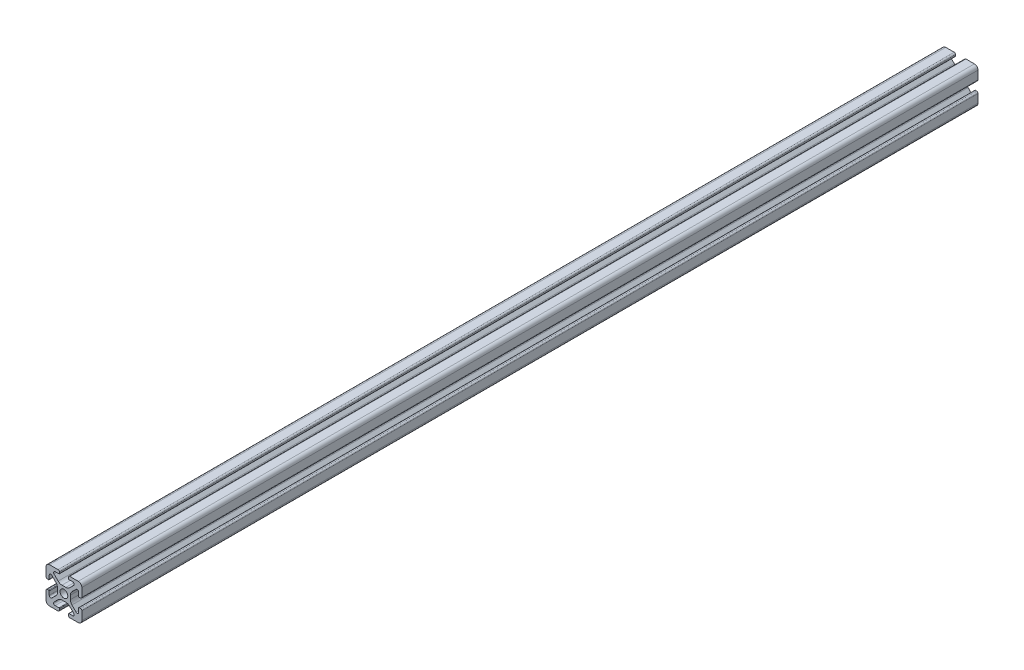
from build123d import *

# Parameters (mm, degrees)
SKETCH3_R                = 2.15
BOSS_EXTRUDE1_DEPTH      = 250
BOSS_EXTRUDE1_DEPTH_BACK = 250


with BuildPart() as part:
    # Sketch3 → Boss-Extrude1 (new body, two sides)
    with BuildSketch(Plane.XY) as boss_extrude1_sk:
        with BuildLine():
            Line((3.2874, 10), (8, 10))
            ThreePointArc((8, 10), (9.414213562, 9.414213562), (10, 8))
            Line((10, 8), (10, 3.2874))
            ThreePointArc((10, 3.2874), (9.76937588, 2.73062412), (9.2126, 2.5))
            Line((9.2126, 2.5), (8.5048, 2.5))
            ThreePointArc((8.5048, 2.5), (8.289273853, 2.589273853), (8.2, 2.8048))
            Line((8.2, 2.8048), (8.2, 4.9118))
            ThreePointArc((8.2, 4.9118), (7.682565253, 5.686195824), (6.769103096, 5.504496904))
            Line((6.769103096, 5.504496904), (4.478679656, 3.214073464))
            ThreePointArc((4.478679656, 3.214073464), (3.828361402, 2.240803418), (3.6, 1.092753121))
            Line((3.6, 1.092753121), (3.6, -1.092753121))
            ThreePointArc((3.6, -1.092753121), (3.828361402, -2.240803418), (4.478679656, -3.214073464))
            Line((4.478679656, -3.214073464), (6.769103096, -5.504496904))
            ThreePointArc((6.769103096, -5.504496904), (7.682565253, -5.686195824), (8.2, -4.9118))
            Line((8.2, -4.9118), (8.2, -2.8048))
            ThreePointArc((8.2, -2.8048), (8.289273853, -2.589273853), (8.5048, -2.5))
            Line((8.5048, -2.5), (9.2126, -2.5))
            ThreePointArc((9.2126, -2.5), (9.76937588, -2.73062412), (10, -3.2874))
            Line((10, -3.2874), (10, -8))
            ThreePointArc((10, -8), (9.414213562, -9.414213562), (8, -10))
            Line((8, -10), (3.2874, -10))
            ThreePointArc((3.2874, -10), (2.73062412, -9.76937588), (2.5, -9.2126))
            Line((2.5, -9.2126), (2.5, -8.5048))
            ThreePointArc((2.5, -8.5048), (2.589273853, -8.289273853), (2.8048, -8.2))
            Line((2.8048, -8.2), (4.9118, -8.2))
            ThreePointArc((4.9118, -8.2), (5.686195824, -7.682565253), (5.504496904, -6.769103096))
            Line((5.504496904, -6.769103096), (3.214073464, -4.478679656))
            ThreePointArc((3.214073464, -4.478679656), (2.240803418, -3.828361402), (1.092753121, -3.6))
            Line((1.092753121, -3.6), (-1.092753121, -3.6))
            ThreePointArc((-1.092753121, -3.6), (-2.240803418, -3.828361402), (-3.214073464, -4.478679656))
            Line((-3.214073464, -4.478679656), (-5.504496904, -6.769103096))
            ThreePointArc((-5.504496904, -6.769103096), (-5.686195824, -7.682565253), (-4.9118, -8.2))
            Line((-4.9118, -8.2), (-2.8048, -8.2))
            ThreePointArc((-2.8048, -8.2), (-2.589273853, -8.289273853), (-2.5, -8.5048))
            Line((-2.5, -8.5048), (-2.5, -9.2126))
            ThreePointArc((-2.5, -9.2126), (-2.73062412, -9.76937588), (-3.2874, -10))
            Line((-3.2874, -10), (-8, -10))
            ThreePointArc((-8, -10), (-9.414213562, -9.414213562), (-10, -8))
            Line((-10, -8), (-10, -3.2874))
            ThreePointArc((-10, -3.2874), (-9.76937588, -2.73062412), (-9.2126, -2.5))
            Line((-9.2126, -2.5), (-8.5048, -2.5))
            ThreePointArc((-8.5048, -2.5), (-8.289273853, -2.589273853), (-8.2, -2.8048))
            Line((-8.2, -2.8048), (-8.2, -4.9118))
            ThreePointArc((-8.2, -4.9118), (-7.682565253, -5.686195824), (-6.769103096, -5.504496904))
            Line((-6.769103096, -5.504496904), (-4.478679656, -3.214073464))
            ThreePointArc((-4.478679656, -3.214073464), (-3.828361402, -2.240803418), (-3.6, -1.092753121))
            Line((-3.6, -1.092753121), (-3.6, 1.092753121))
            ThreePointArc((-3.6, 1.092753121), (-3.828361402, 2.240803418), (-4.478679656, 3.214073464))
            Line((-4.478679656, 3.214073464), (-6.769103096, 5.504496904))
            ThreePointArc((-6.769103096, 5.504496904), (-7.682565253, 5.686195824), (-8.2, 4.9118))
            Line((-8.2, 4.9118), (-8.2, 2.8048))
            ThreePointArc((-8.2, 2.8048), (-8.289273853, 2.589273853), (-8.5048, 2.5))
            Line((-8.5048, 2.5), (-9.2126, 2.5))
            ThreePointArc((-9.2126, 2.5), (-9.76937588, 2.73062412), (-10, 3.2874))
            Line((-10, 3.2874), (-10, 8))
            ThreePointArc((-10, 8), (-9.414213562, 9.414213562), (-8, 10))
            Line((-8, 10), (-3.2874, 10))
            ThreePointArc((-3.2874, 10), (-2.73062412, 9.76937588), (-2.5, 9.2126))
            Line((-2.5, 9.2126), (-2.5, 8.5048))
            ThreePointArc((-2.5, 8.5048), (-2.589273853, 8.289273853), (-2.8048, 8.2))
            Line((-2.8048, 8.2), (-4.9118, 8.2))
            ThreePointArc((-4.9118, 8.2), (-5.686195824, 7.682565253), (-5.504496904, 6.769103096))
            Line((-5.504496904, 6.769103096), (-3.214073464, 4.478679656))
            ThreePointArc((-3.214073464, 4.478679656), (-2.240803418, 3.828361402), (-1.092753121, 3.6))
            Line((-1.092753121, 3.6), (1.092753121, 3.6))
            ThreePointArc((1.092753121, 3.6), (2.240803418, 3.828361402), (3.214073464, 4.478679656))
            Line((3.214073464, 4.478679656), (5.504496904, 6.769103096))
            ThreePointArc((5.504496904, 6.769103096), (5.686195824, 7.682565253), (4.9118, 8.2))
            Line((4.9118, 8.2), (2.8048, 8.2))
            ThreePointArc((2.8048, 8.2), (2.589273853, 8.289273853), (2.5, 8.5048))
            Line((2.5, 8.5048), (2.5, 9.2126))
            ThreePointArc((2.5, 9.2126), (2.73062412, 9.76937588), (3.2874, 10))
        make_face()
        Circle(SKETCH3_R, mode=Mode.SUBTRACT)
    extrude(amount=BOSS_EXTRUDE1_DEPTH)
    extrude(boss_extrude1_sk.sketch, amount=-BOSS_EXTRUDE1_DEPTH_BACK)


solid = part.part
